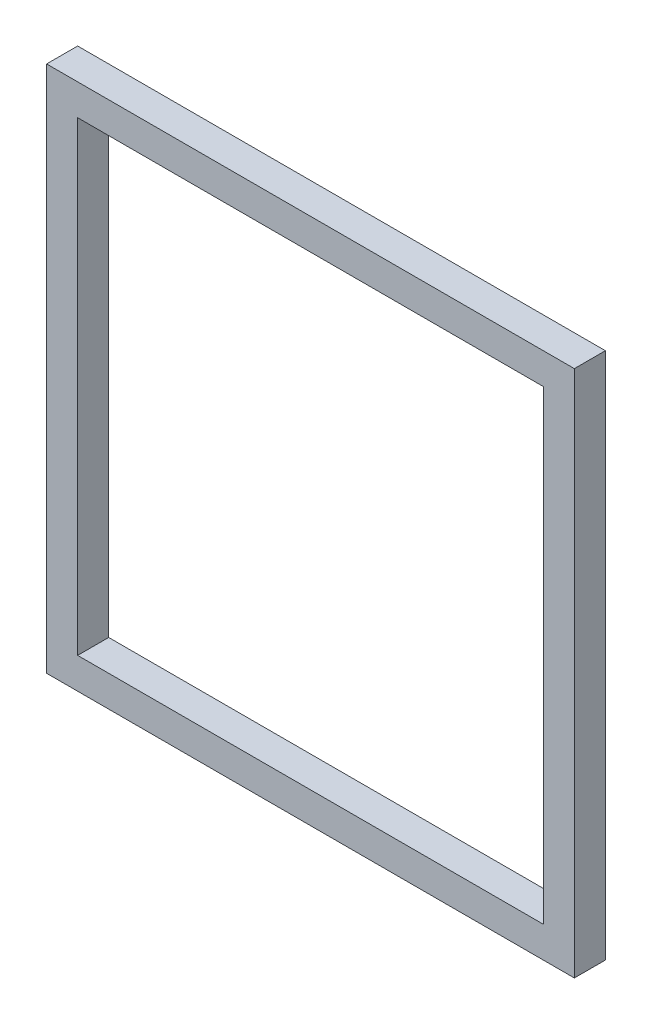
from build123d import *

# Parameters (mm, degrees)
SKETCH1_W           = 340
SKETCH1_H           = 340
SKETCH1_W_2         = 300
SKETCH1_H_2         = 300
BOSS_EXTRUDE1_DEPTH = 20


with BuildPart() as part:
    # Sketch1 → Boss-Extrude1 (new body)
    with BuildSketch(Plane.XY):
        with Locations((170, -170)):
            Rectangle(SKETCH1_W, SKETCH1_H)
        with Locations((170, -170)):
            Rectangle(SKETCH1_W_2, SKETCH1_H_2, mode=Mode.SUBTRACT)
    extrude(amount=BOSS_EXTRUDE1_DEPTH)


solid = part.part
